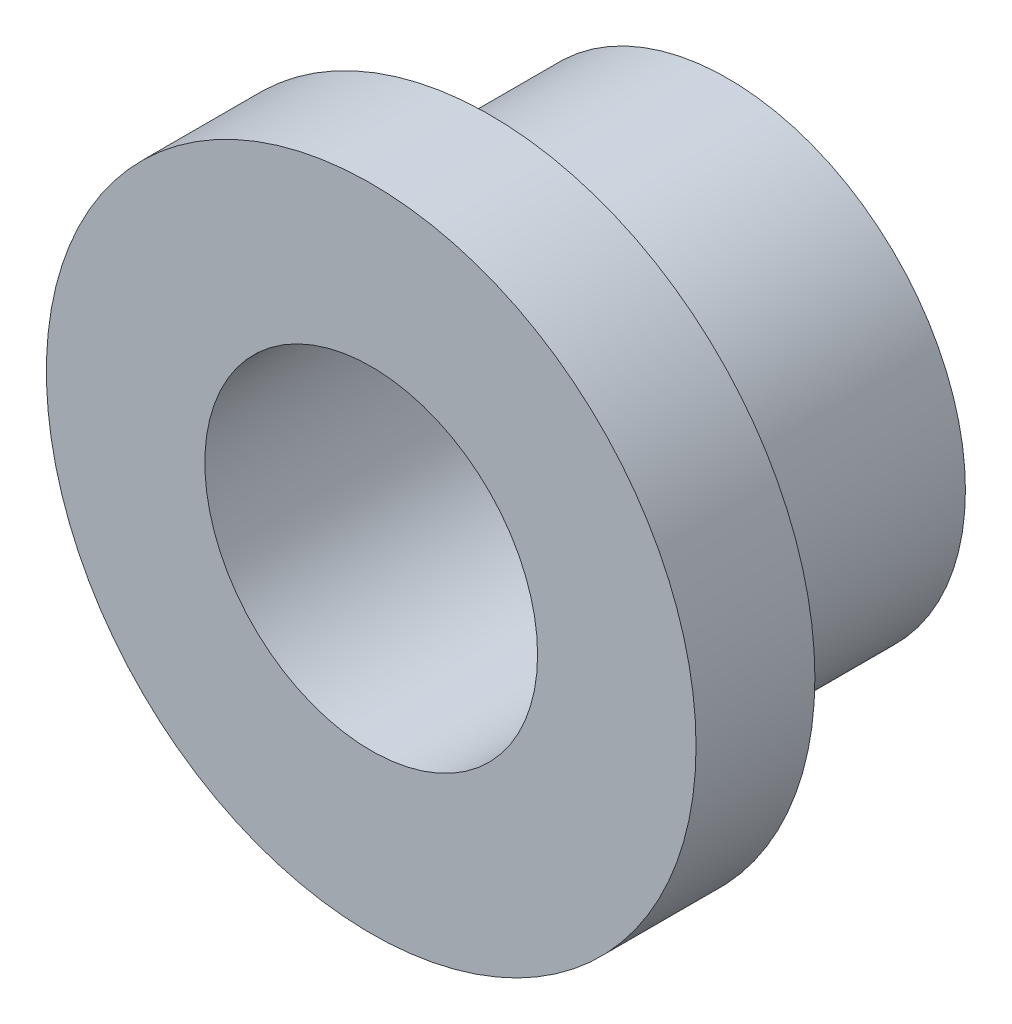
from build123d import *


with BuildPart() as part:
    # Sketch1 → Revolve1 (revolve)
    with BuildSketch(Plane(origin=(0, 0, 0), x_dir=(0, 0, -1), z_dir=(1, 0, 0))):
        Polygon((0, 2.1), (0, 4.1), (1.5, 4.1), (1.5, 3), (4.5, 3), (4.5, 2.1), align=None)
    revolve(axis=Axis((0, 0, 8.030450487), (0, 0, -1)))


solid = part.part
